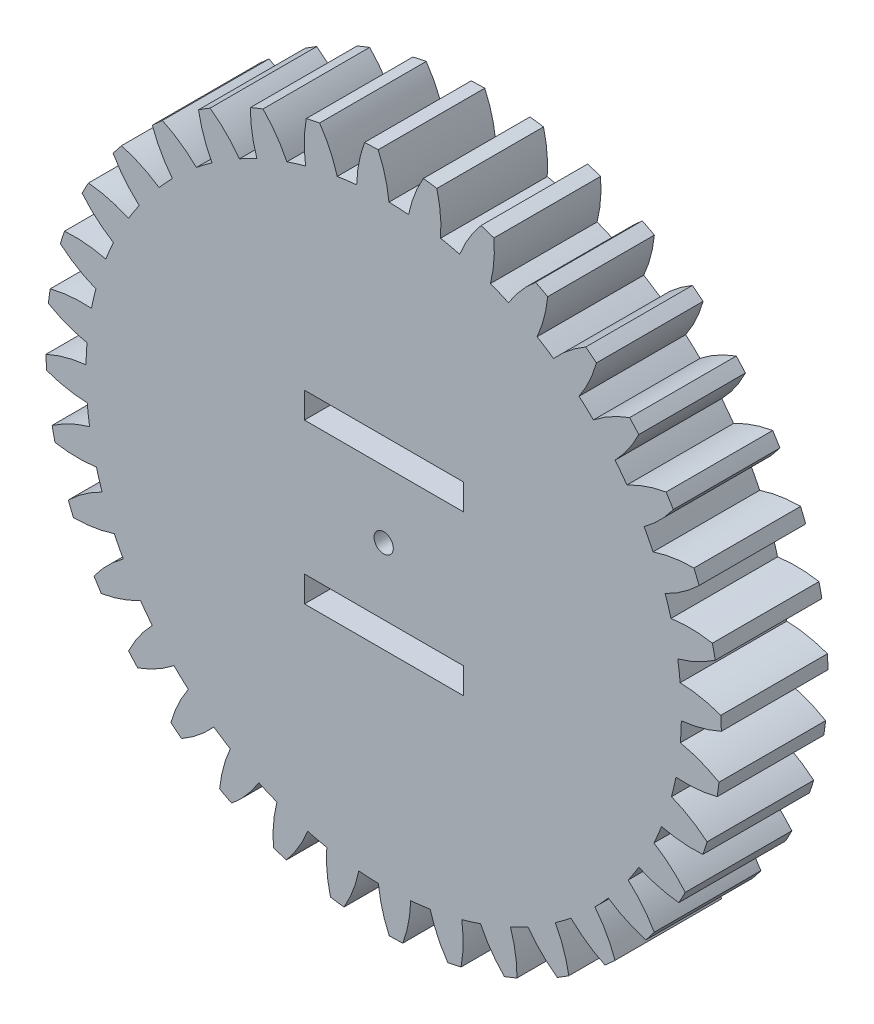
from build123d import *

# Parameters (mm, degrees)
SKETCH1_R           = 0.396875
BOSS_EXTRUDE1_DEPTH = 25.4
SKETCH2_R           = 2.29235
SKETCH2_W           = 37.9222
SKETCH2_H           = 6.1722
CUT_EXTRUDE1_DEPTH  = 26.4


with BuildPart() as part:
    # Sketch1 → Boss-Extrude1 (new body)
    with BuildSketch(Plane(origin=(0, 0, 0), x_dir=(-1, 0, 0), z_dir=(0, 0, -1))):
        with BuildLine():
            ThreePointArc((-79.429096867, -12.670425488), (-74.550376957, -13.512297805), (-69.599722373, -13.553238584))
            ThreePointArc((-69.599722373, -13.553238584), (-69.116134344, -15.835769761), (-68.557711605, -18.101154937))
            ThreePointArc((-68.557711605, -18.101154937), (-72.996694845, -20.293433376), (-77.022208676, -23.175428405))
            ThreePointArc((-77.022208676, -23.175428405), (-76.537849508, -24.728095435), (-76.022194113, -26.270651179))
            ThreePointArc((-76.022194113, -26.270651179), (-71.071403327, -26.252552743), (-66.188851019, -25.433199393))
            ThreePointArc((-66.188851019, -25.433199393), (-65.316252399, -27.597079611), (-64.372933349, -29.731079406))
            ThreePointArc((-64.372933349, -29.731079406), (-68.363793303, -32.660873559), (-71.827697349, -36.198107749))
            ThreePointArc((-71.827697349, -36.198107749), (-71.081078885, -37.643078191), (-70.30539546, -39.072656428))
            ThreePointArc((-70.30539546, -39.072656428), (-65.432961071, -38.195137149), (-60.76686492, -36.540385307))
            ThreePointArc((-60.76686492, -36.540385307), (-59.531769177, -38.519866163), (-58.232216087, -40.457640071))
            ThreePointArc((-58.232216087, -40.457640071), (-61.653692496, -44.035929627), (-64.450737785, -48.120925906))
            ThreePointArc((-64.450737785, -48.120925906), (-63.464545648, -49.414295065), (-62.452402942, -50.687458783))
            ThreePointArc((-62.452402942, -50.687458783), (-57.806371404, -48.977181641), (-53.498508379, -46.537310104))
            ThreePointArc((-53.498508379, -46.537310104), (-51.938443273, -48.272246073), (-50.322142407, -49.954915816))
            ThreePointArc((-50.322142407, -49.954915816), (-53.07027544, -54.072976256), (-55.115475167, -58.58161408))
            ThreePointArc((-55.115475167, -58.58161408), (-53.919674307, -59.684083588), (-52.701825764, -60.762148352))
            ThreePointArc((-52.701825764, -60.762148352), (-48.423364393, -58.271079253), (-44.604626734, -55.120222283))
            ThreePointArc((-44.604626734, -55.120222283), (-42.766994052, -56.557898213), (-40.883055893, -57.934336722))
            ThreePointArc((-40.883055893, -57.934336722), (-42.87434492, -62.467042863), (-44.105556725, -67.262329554))
            ThreePointArc((-44.105556725, -67.262329554), (-42.736480947, -68.140401432), (-41.349930277, -68.99061079))
            ThreePointArc((-41.349930277, -68.99061079), (-37.569037958, -65.794439608), (-34.355456075, -62.0283344))
            ThreePointArc((-34.355456075, -62.0283344), (-32.296091358, -63.125067236), (-30.201758415, -64.153452122))
            ThreePointArc((-30.201758415, -64.153452122), (-31.375699125, -68.963079984), (-31.755513261, -73.899313181))
            ThreePointArc((-31.755513261, -73.899313181), (-30.254761239, -74.52630766), (-28.741638084, -75.12282843))
            ThreePointArc((-28.741638084, -75.12282843), (-25.573195316, -71.318669209), (-23.062412269, -67.051746964))
            ThreePointArc((-23.062412269, -67.051746964), (-20.843888271, -67.774213034), (-18.602795789, -68.423297344))
            ThreePointArc((-18.602795789, -68.423297344), (-18.923718589, -73.363708816), (-18.440594596, -78.290903572))
            ThreePointArc((-18.440594596, -78.290903572), (-16.85376592, -78.647769742), (-15.260045761, -78.972476943))
            ThreePointArc((-15.260045761, -78.972476943), (-12.800324074, -74.675917135), (-11.068628736, -70.037826126))
            ThreePointArc((-11.068628736, -70.037826126), (-8.758354186, -70.364073663), (-6.438596627, -70.614135299))
            ThreePointArc((-6.438596627, -70.614135299), (-5.89675044, -75.535218479), (-4.565367795, -80.303664474))
            ThreePointArc((-4.565367795, -80.303664474), (-2.940677452, -80.379559138), (-1.31478467, -80.422586705))
            ThreePointArc((-1.31478467, -80.422586705), (0.361478537, -75.764175107), (1.26146948, -70.895841382))
            ThreePointArc((1.26146948, -70.895841382), (3.593298059, -70.815957521), (5.921236035, -70.659398486))
            ThreePointArc((5.921236035, -70.659398486), (7.309387488, -75.411628752), (9.448575396, -79.876439168))
            ThreePointArc((9.448575396, -79.876439168), (11.061762012, -79.669056304), (12.670425488, -79.429096867))
            ThreePointArc((12.670425488, -79.429096867), (13.512297805, -74.550376957), (13.553238584, -69.599722373))
            ThreePointArc((13.553238584, -69.599722373), (15.835769761, -69.116134344), (18.101154937, -68.557711605))
            ThreePointArc((18.101154937, -68.557711605), (20.293433376, -72.996694845), (23.175428405, -77.022208676))
            ThreePointArc((23.175428405, -77.022208676), (24.728095435, -76.537849508), (26.270651179, -76.022194113))
            ThreePointArc((26.270651179, -76.022194113), (26.252552743, -71.071403327), (25.433199393, -66.188851019))
            ThreePointArc((25.433199393, -66.188851019), (27.597079611, -65.316252399), (29.731079406, -64.372933349))
            ThreePointArc((29.731079406, -64.372933349), (32.660873559, -68.363793303), (36.198107749, -71.827697349))
            ThreePointArc((36.198107749, -71.827697349), (37.643078191, -71.081078885), (39.072656428, -70.30539546))
            ThreePointArc((39.072656428, -70.30539546), (38.195137149, -65.432961071), (36.540385307, -60.76686492))
            ThreePointArc((36.540385307, -60.76686492), (38.519866163, -59.531769177), (40.457640071, -58.232216087))
            ThreePointArc((40.457640071, -58.232216087), (44.035929627, -61.653692496), (48.120925906, -64.450737785))
            ThreePointArc((48.120925906, -64.450737785), (49.414295065, -63.464545648), (50.687458783, -62.452402942))
            ThreePointArc((50.687458783, -62.452402942), (48.977181641, -57.806371404), (46.537310104, -53.498508379))
            ThreePointArc((46.537310104, -53.498508379), (48.272246073, -51.938443273), (49.954915816, -50.322142407))
            ThreePointArc((49.954915816, -50.322142407), (54.072976256, -53.07027544), (58.58161408, -55.115475167))
            ThreePointArc((58.58161408, -55.115475167), (59.684083588, -53.919674307), (60.762148352, -52.701825764))
            ThreePointArc((60.762148352, -52.701825764), (58.271079253, -48.423364393), (55.120222283, -44.604626734))
            ThreePointArc((55.120222283, -44.604626734), (56.557898213, -42.766994052), (57.934336722, -40.883055893))
            ThreePointArc((57.934336722, -40.883055893), (62.467042863, -42.87434492), (67.262329554, -44.105556725))
            ThreePointArc((67.262329554, -44.105556725), (68.140401432, -42.736480947), (68.99061079, -41.349930277))
            ThreePointArc((68.99061079, -41.349930277), (65.794439608, -37.569037958), (62.0283344, -34.355456075))
            ThreePointArc((62.0283344, -34.355456075), (63.125067236, -32.296091358), (64.153452122, -30.201758415))
            ThreePointArc((64.153452122, -30.201758415), (68.963079984, -31.375699125), (73.899313181, -31.755513261))
            ThreePointArc((73.899313181, -31.755513261), (74.52630766, -30.254761239), (75.12282843, -28.741638084))
            ThreePointArc((75.12282843, -28.741638084), (71.318669209, -25.573195316), (67.051746964, -23.062412269))
            ThreePointArc((67.051746964, -23.062412269), (67.774213034, -20.843888271), (68.423297344, -18.602795789))
            ThreePointArc((68.423297344, -18.602795789), (73.363708816, -18.923718589), (78.290903572, -18.440594596))
            ThreePointArc((78.290903572, -18.440594596), (78.647769742, -16.85376592), (78.972476943, -15.260045761))
            ThreePointArc((78.972476943, -15.260045761), (74.675917135, -12.800324074), (70.037826126, -11.068628736))
            ThreePointArc((70.037826126, -11.068628736), (70.364073663, -8.758354186), (70.614135299, -6.438596627))
            ThreePointArc((70.614135299, -6.438596627), (75.535218479, -5.89675044), (80.303664474, -4.565367795))
            ThreePointArc((80.303664474, -4.565367795), (80.379559138, -2.940677452), (80.422586705, -1.31478467))
            ThreePointArc((80.422586705, -1.31478467), (75.764175107, 0.361478537), (70.895841382, 1.26146948))
            ThreePointArc((70.895841382, 1.26146948), (70.815957521, 3.593298059), (70.659398486, 5.921236035))
            ThreePointArc((70.659398486, 5.921236035), (75.411628752, 7.309387488), (79.876439168, 9.448575396))
            ThreePointArc((79.876439168, 9.448575396), (79.669056304, 11.061762012), (79.429096867, 12.670425488))
            ThreePointArc((79.429096867, 12.670425488), (74.550376957, 13.512297805), (69.599722373, 13.553238584))
            ThreePointArc((69.599722373, 13.553238584), (69.116134344, 15.835769761), (68.557711605, 18.101154937))
            ThreePointArc((68.557711605, 18.101154937), (72.996694845, 20.293433376), (77.022208676, 23.175428405))
            ThreePointArc((77.022208676, 23.175428405), (76.537849508, 24.728095435), (76.022194113, 26.270651179))
            ThreePointArc((76.022194113, 26.270651179), (71.071403327, 26.252552743), (66.188851019, 25.433199393))
            ThreePointArc((66.188851019, 25.433199393), (65.316252399, 27.597079611), (64.372933349, 29.731079406))
            ThreePointArc((64.372933349, 29.731079406), (68.363793303, 32.660873559), (71.827697349, 36.198107749))
            ThreePointArc((71.827697349, 36.198107749), (71.081078885, 37.643078191), (70.30539546, 39.072656428))
            ThreePointArc((70.30539546, 39.072656428), (65.432961071, 38.195137149), (60.76686492, 36.540385307))
            ThreePointArc((60.76686492, 36.540385307), (59.531769177, 38.519866163), (58.232216087, 40.457640071))
            ThreePointArc((58.232216087, 40.457640071), (61.653692496, 44.035929627), (64.450737785, 48.120925906))
            ThreePointArc((64.450737785, 48.120925906), (63.464545648, 49.414295065), (62.452402942, 50.687458783))
            ThreePointArc((62.452402942, 50.687458783), (57.806371404, 48.977181641), (53.498508379, 46.537310104))
            ThreePointArc((53.498508379, 46.537310104), (51.938443273, 48.272246073), (50.322142407, 49.954915816))
            ThreePointArc((50.322142407, 49.954915816), (53.07027544, 54.072976256), (55.115475167, 58.58161408))
            ThreePointArc((55.115475167, 58.58161408), (53.919674307, 59.684083588), (52.701825764, 60.762148352))
            ThreePointArc((52.701825764, 60.762148352), (48.423364393, 58.271079253), (44.604626734, 55.120222283))
            ThreePointArc((44.604626734, 55.120222283), (42.766994052, 56.557898213), (40.883055893, 57.934336722))
            ThreePointArc((40.883055893, 57.934336722), (42.87434492, 62.467042863), (44.105556725, 67.262329554))
            ThreePointArc((44.105556725, 67.262329554), (42.736480947, 68.140401432), (41.349930277, 68.99061079))
            ThreePointArc((41.349930277, 68.99061079), (37.569037958, 65.794439608), (34.355456075, 62.0283344))
            ThreePointArc((34.355456075, 62.0283344), (32.296091358, 63.125067236), (30.201758415, 64.153452122))
            ThreePointArc((30.201758415, 64.153452122), (31.375699125, 68.963079984), (31.755513261, 73.899313181))
            ThreePointArc((31.755513261, 73.899313181), (30.254761239, 74.52630766), (28.741638084, 75.12282843))
            ThreePointArc((28.741638084, 75.12282843), (25.573195316, 71.318669209), (23.062412269, 67.051746964))
            ThreePointArc((23.062412269, 67.051746964), (20.843888271, 67.774213034), (18.602795789, 68.423297344))
            ThreePointArc((18.602795789, 68.423297344), (18.923718589, 73.363708816), (18.440594596, 78.290903572))
            ThreePointArc((18.440594596, 78.290903572), (16.85376592, 78.647769742), (15.260045761, 78.972476943))
            ThreePointArc((15.260045761, 78.972476943), (12.800324074, 74.675917135), (11.068628736, 70.037826126))
            ThreePointArc((11.068628736, 70.037826126), (8.758354186, 70.364073663), (6.438596627, 70.614135299))
            ThreePointArc((6.438596627, 70.614135299), (5.89675044, 75.535218479), (4.565367795, 80.303664474))
            ThreePointArc((4.565367795, 80.303664474), (2.940677452, 80.379559138), (1.31478467, 80.422586705))
            ThreePointArc((1.31478467, 80.422586705), (-0.361478537, 75.764175107), (-1.26146948, 70.895841382))
            ThreePointArc((-1.26146948, 70.895841382), (-3.593298059, 70.815957521), (-5.921236035, 70.659398486))
            ThreePointArc((-5.921236035, 70.659398486), (-7.309387488, 75.411628752), (-9.448575396, 79.876439168))
            ThreePointArc((-9.448575396, 79.876439168), (-11.061762012, 79.669056304), (-12.670425488, 79.429096867))
            ThreePointArc((-12.670425488, 79.429096867), (-13.512297805, 74.550376957), (-13.553238584, 69.599722373))
            ThreePointArc((-13.553238584, 69.599722373), (-15.835769761, 69.116134344), (-18.101154937, 68.557711605))
            ThreePointArc((-18.101154937, 68.557711605), (-20.293433376, 72.996694845), (-23.175428405, 77.022208676))
            ThreePointArc((-23.175428405, 77.022208676), (-24.728095435, 76.537849508), (-26.270651179, 76.022194113))
            ThreePointArc((-26.270651179, 76.022194113), (-26.252552743, 71.071403327), (-25.433199393, 66.188851019))
            ThreePointArc((-25.433199393, 66.188851019), (-27.597079611, 65.316252399), (-29.731079406, 64.372933349))
            ThreePointArc((-29.731079406, 64.372933349), (-32.660873559, 68.363793303), (-36.198107749, 71.827697349))
            ThreePointArc((-36.198107749, 71.827697349), (-37.643078191, 71.081078885), (-39.072656428, 70.30539546))
            ThreePointArc((-39.072656428, 70.30539546), (-38.195137149, 65.432961071), (-36.540385307, 60.76686492))
            ThreePointArc((-36.540385307, 60.76686492), (-38.519866163, 59.531769177), (-40.457640071, 58.232216087))
            ThreePointArc((-40.457640071, 58.232216087), (-44.035929627, 61.653692496), (-48.120925906, 64.450737785))
            ThreePointArc((-48.120925906, 64.450737785), (-49.414295065, 63.464545648), (-50.687458783, 62.452402942))
            ThreePointArc((-50.687458783, 62.452402942), (-48.977181641, 57.806371404), (-46.537310104, 53.498508379))
            ThreePointArc((-46.537310104, 53.498508379), (-48.272246073, 51.938443273), (-49.954915816, 50.322142407))
            ThreePointArc((-49.954915816, 50.322142407), (-54.072976256, 53.07027544), (-58.58161408, 55.115475167))
            ThreePointArc((-58.58161408, 55.115475167), (-59.684083588, 53.919674307), (-60.762148352, 52.701825764))
            ThreePointArc((-60.762148352, 52.701825764), (-58.271079253, 48.423364393), (-55.120222283, 44.604626734))
            ThreePointArc((-55.120222283, 44.604626734), (-56.557898213, 42.766994052), (-57.934336722, 40.883055893))
            ThreePointArc((-57.934336722, 40.883055893), (-62.467042863, 42.87434492), (-67.262329554, 44.105556725))
            ThreePointArc((-67.262329554, 44.105556725), (-68.140401432, 42.736480947), (-68.99061079, 41.349930277))
            ThreePointArc((-68.99061079, 41.349930277), (-65.794439608, 37.569037958), (-62.0283344, 34.355456075))
            ThreePointArc((-62.0283344, 34.355456075), (-63.125067236, 32.296091358), (-64.153452122, 30.201758415))
            ThreePointArc((-64.153452122, 30.201758415), (-68.963079984, 31.375699125), (-73.899313181, 31.755513261))
            ThreePointArc((-73.899313181, 31.755513261), (-74.52630766, 30.254761239), (-75.12282843, 28.741638084))
            ThreePointArc((-75.12282843, 28.741638084), (-71.318669209, 25.573195316), (-67.051746964, 23.062412269))
            ThreePointArc((-67.051746964, 23.062412269), (-67.774213034, 20.843888271), (-68.423297344, 18.602795789))
            ThreePointArc((-68.423297344, 18.602795789), (-73.363708816, 18.923718589), (-78.290903572, 18.440594596))
            ThreePointArc((-78.290903572, 18.440594596), (-78.647769742, 16.85376592), (-78.972476943, 15.260045761))
            ThreePointArc((-78.972476943, 15.260045761), (-74.675917135, 12.800324074), (-70.037826126, 11.068628736))
            ThreePointArc((-70.037826126, 11.068628736), (-70.364073663, 8.758354186), (-70.614135299, 6.438596627))
            ThreePointArc((-70.614135299, 6.438596627), (-75.535218479, 5.89675044), (-80.303664474, 4.565367795))
            ThreePointArc((-80.303664474, 4.565367795), (-80.379559138, 2.940677452), (-80.422586705, 1.31478467))
            ThreePointArc((-80.422586705, 1.31478467), (-75.764175107, -0.361478537), (-70.895841382, -1.26146948))
            ThreePointArc((-70.895841382, -1.26146948), (-70.815957521, -3.593298059), (-70.659398486, -5.921236035))
            ThreePointArc((-70.659398486, -5.921236035), (-75.411628752, -7.309387488), (-79.876439168, -9.448575396))
            ThreePointArc((-79.876439168, -9.448575396), (-79.669056304, -11.061762012), (-79.429096867, -12.670425488))
        make_face()
        Circle(SKETCH1_R, mode=Mode.SUBTRACT)
    extrude(amount=-BOSS_EXTRUDE1_DEPTH)

    # Sketch2 → Cut-Extrude1 (cut, through all)
    with BuildSketch(Plane.XY.offset(25.4)):
        Circle(SKETCH2_R)
        with Locations((0.0889, 18.9611)):
            Rectangle(SKETCH2_W, SKETCH2_H)
        with Locations((0.0889, -18.9611)):
            Rectangle(SKETCH2_W, SKETCH2_H)
    extrude(amount=-CUT_EXTRUDE1_DEPTH, mode=Mode.SUBTRACT)


solid = part.part
